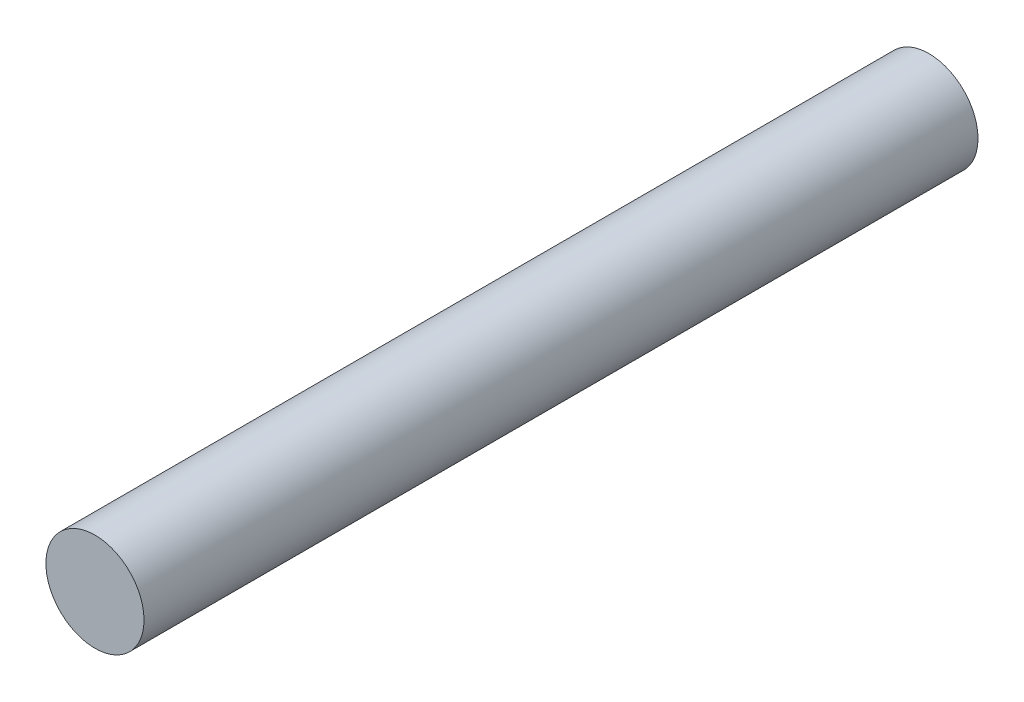
from build123d import *

# Parameters (mm, degrees)
ESQUISSE1_R        = 2
BOSS_EXTRU_2_DEPTH = 34


with BuildPart() as part:
    # Esquisse1 → Boss.-Extru.2 (new body)
    with BuildSketch(Plane.XY):
        Circle(ESQUISSE1_R)
    extrude(amount=BOSS_EXTRU_2_DEPTH)


solid = part.part
